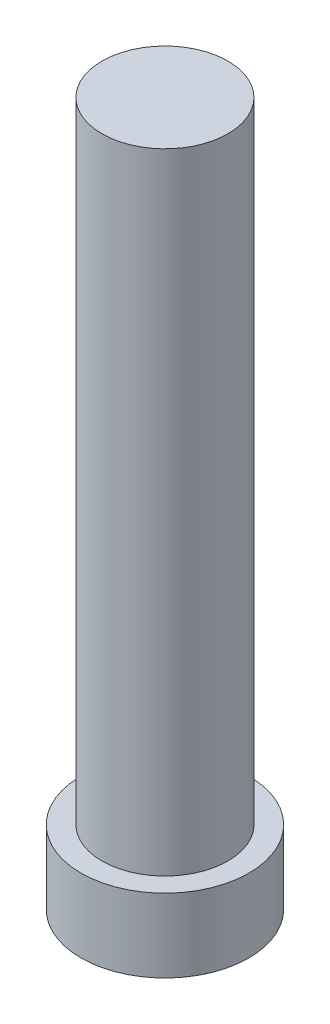
from build123d import *

# Parameters (mm, degrees)
SKETCH1_R           = 8
BOSS_EXTRUDE1_DEPTH = 3.5
SKETCH2_R           = 6
BOSS_EXTRUDE2_DEPTH = 60


with BuildPart() as part:
    # Sketch1 → Boss-Extrude1 (new body, symmetric)
    with BuildSketch(Plane(origin=(0, 0, 0), x_dir=(1, 0, 0), z_dir=(0, 1, 0))):
        Circle(SKETCH1_R)
    extrude(amount=BOSS_EXTRUDE1_DEPTH, both=True)

    # Sketch2 → Boss-Extrude2 (add)
    with BuildSketch(Plane(origin=(0, 3.5, 0), x_dir=(1, 0, 0), z_dir=(0, 1, 0))):
        Circle(SKETCH2_R)
    extrude(amount=BOSS_EXTRUDE2_DEPTH)


solid = part.part
